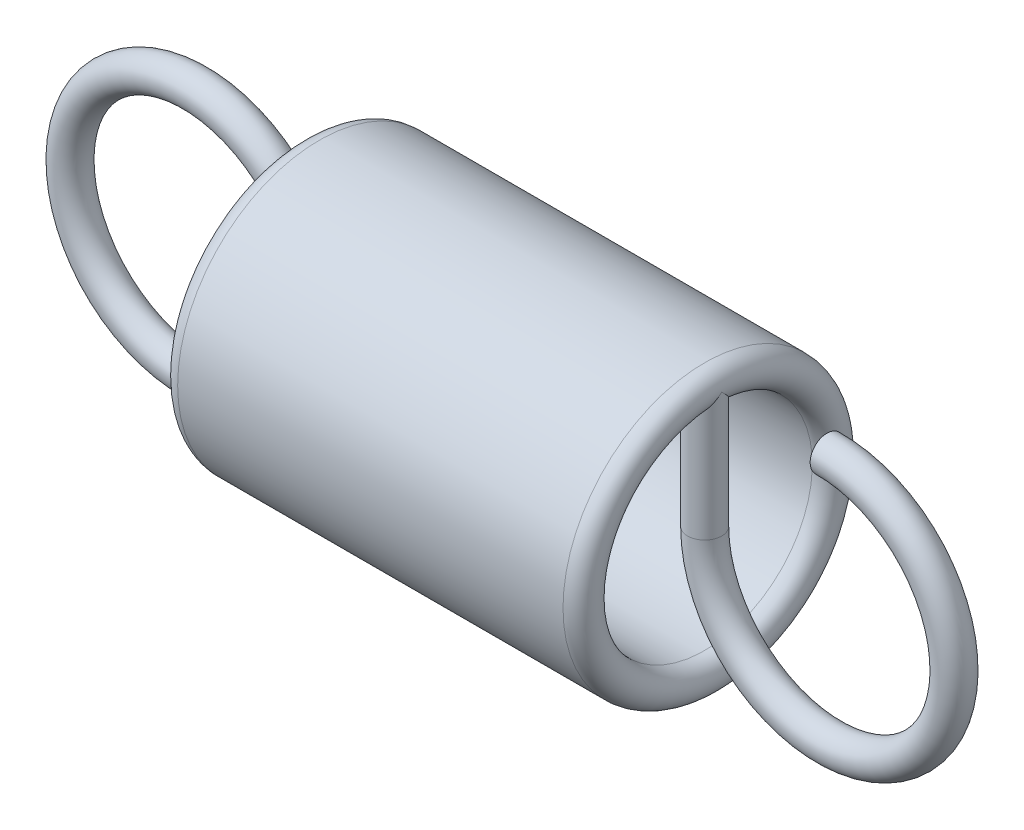
from build123d import *

# Parameters (mm, degrees)
SKETCH2_W      = 0.3
SKETCH2_H      = 2.2
SKETCH3_R      = 0.3
REVOLVE3_ANGLE = 271
SKETCH4_W      = 0.3
SKETCH4_H      = 2.2
SKETCH5_R      = 0.3
REVOLVE5_ANGLE = 271


with BuildPart() as part:
    # Sketch1 → Revolve1 (revolve)
    with BuildSketch(Plane.XY):
        with BuildLine():
            Line((4.1, 1.9), (10.9, 1.9))
            ThreePointArc((10.9, 1.9), (11.2, 2.2), (10.9, 2.5))
            Line((10.9, 2.5), (4.1, 2.5))
            ThreePointArc((4.1, 2.5), (3.8, 2.2), (4.1, 1.9))
        make_face()
    revolve(axis=Axis((11.2, 0, 0), (-1, 0, 0)))

    # Sketch2 → Revolve2 (revolve)
    with BuildSketch(Plane.XY):
        with Locations((11.05, 1.1)):
            Rectangle(SKETCH2_W, SKETCH2_H)
    revolve(axis=Axis((10.9, 0, 0), (0, 1, 0)))

    # Sketch3 → Revolve3 (revolve)
    with BuildSketch(Plane(origin=(0, 0, 0), x_dir=(-1, 0, 0), z_dir=(0, 1, 0))):
        with Locations((-10.9, 0)):
            Circle(SKETCH3_R)
    revolve(axis=Axis((13.1, 0, -2.5), (0, 0, 1)), revolution_arc=REVOLVE3_ANGLE)

    # Sketch4 → Revolve4 (revolve)
    with BuildSketch(Plane.XY):
        with Locations((4.25, -1.1)):
            Rectangle(SKETCH4_W, SKETCH4_H)
    revolve(axis=Axis((4.1, -2.2, 0), (0, 1, 0)))

    # Sketch5 → Revolve5 (revolve)
    with BuildSketch(Plane(origin=(0, 0, 0), x_dir=(-1, 0, 0), z_dir=(0, 1, 0))):
        with Locations((-4.1, 0)):
            Circle(SKETCH5_R)
    revolve(axis=Axis((1.9, 0, 2.5), (0, 0, 1)), revolution_arc=REVOLVE5_ANGLE)


solid = part.part
